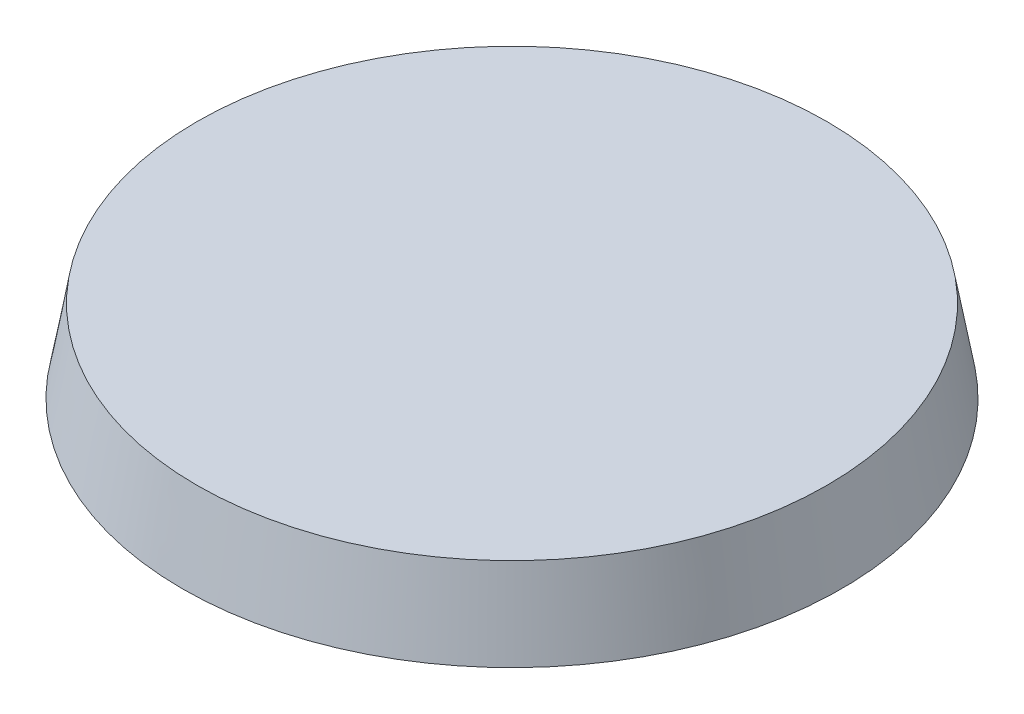
from build123d import *

# Parameters (mm, degrees)
SKETCH_1_R      = 14
EXTRUDE_1_DEPTH = 3.5
EXTRUDE_1_TAPER = 10


with BuildPart() as part:
    # Эскиз1 → Бобышка-Вытянуть1 (new body)
    with BuildSketch(Plane(origin=(0, 0, 0), x_dir=(1, 0, 0), z_dir=(0, 1, 0))):
        Circle(SKETCH_1_R)
    extrude(amount=EXTRUDE_1_DEPTH, taper=EXTRUDE_1_TAPER)


solid = part.part
